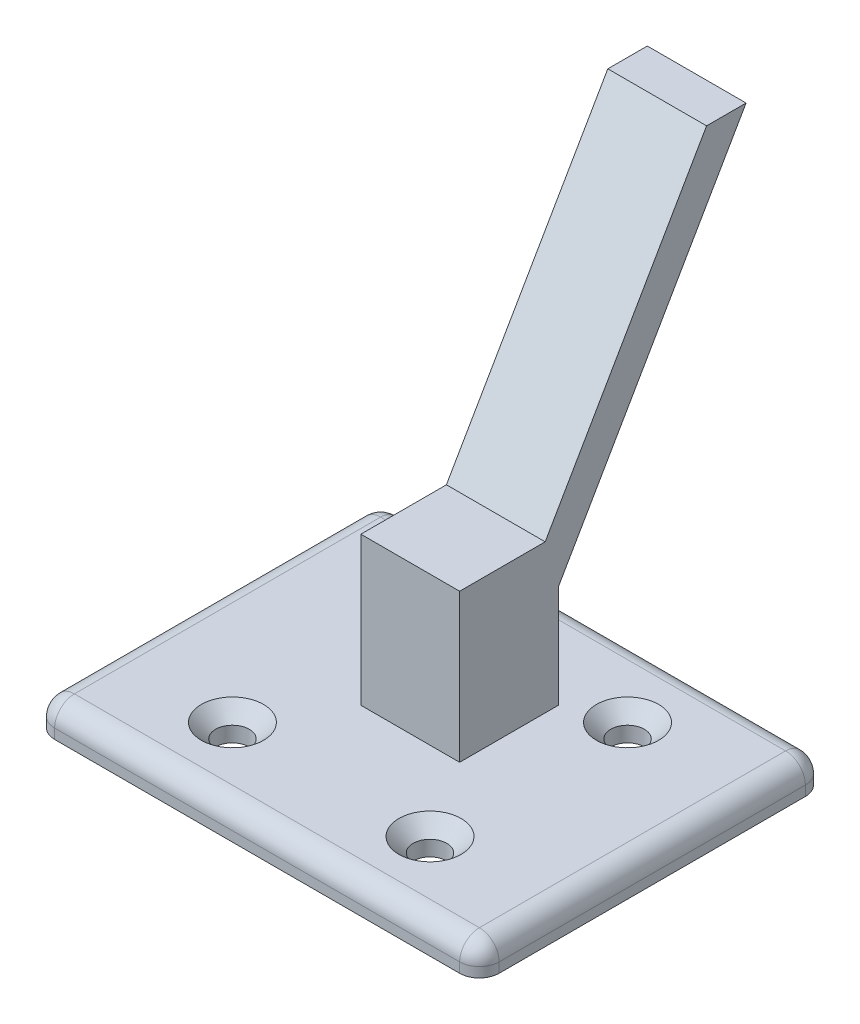
from build123d import *

# Parameters (mm, degrees)
SKETCH1_W                                      = 45
SKETCH1_H                                      = 35
BOSS_EXTRUDE1_DEPTH                            = 3
CSK_FOR_M3_FLAT_HEAD_MACHINE_SCREW2_AT_2_COUNT = 2
CSK_FOR_M3_FLAT_HEAD_MACHINE_SCREW2_AT_2_PITCH = 20
CSK_FOR_M3_FLAT_HEAD_MACHINE_SCREW2_AT_3_COUNT = 2
CSK_FOR_M3_FLAT_HEAD_MACHINE_SCREW2_AT_3_PITCH = 28.284271247
CSK_FOR_M3_FLAT_HEAD_MACHINE_SCREW2_AT_4_COUNT = 2
CSK_FOR_M3_FLAT_HEAD_MACHINE_SCREW2_AT_4_PITCH = 20
SKETCH7_W                                      = 10
SKETCH7_H                                      = 4
BOSS_EXTRUDE2_DEPTH                            = 50
FILLET1_R                                      = 2
SKETCH12_W                                     = 10
SKETCH12_H                                     = 10
BOSS_EXTRUDE3_DEPTH                            = 15


with BuildPart() as part:
    # Sketch1 → Boss-Extrude1 (new body)
    with BuildSketch(Plane(origin=(0, 0, 0), x_dir=(1, 0, 0), z_dir=(0, 1, 0))):
        Rectangle(SKETCH1_W, SKETCH1_H)
    extrude(amount=BOSS_EXTRUDE1_DEPTH)

    # Sketch5 → CSK for M3 Flat Head Machine Screw2 (revolve, cut)
    with BuildSketch(Plane(origin=(10, 3, -10), x_dir=(0, 0, 1), z_dir=(1, 0, 0))):
        Polygon((0, 0), (0, 3), (1.7, 3), (1.7, 1.45), (3.15, 0), align=None)
    csk_for_m3_flat_head_machine_screw2 = revolve(axis=Axis((10, 9.35, -10), (0, -1, 0)), mode=Mode.SUBTRACT)

    # CSK for M3 Flat Head Machine Screw2 at 2: CSK for M3 Flat Head Machine Screw2 ×2
    with Locations(*[(-i * CSK_FOR_M3_FLAT_HEAD_MACHINE_SCREW2_AT_2_PITCH, 0, 0) for i in range(1, CSK_FOR_M3_FLAT_HEAD_MACHINE_SCREW2_AT_2_COUNT)]):
        add(csk_for_m3_flat_head_machine_screw2, mode=Mode.SUBTRACT)

    # CSK for M3 Flat Head Machine Screw2 at 3: CSK for M3 Flat Head Machine Screw2 ×2
    with Locations(*[Vector(-0.707106781, 0, 0.707106781) * (i * CSK_FOR_M3_FLAT_HEAD_MACHINE_SCREW2_AT_3_PITCH) for i in range(1, CSK_FOR_M3_FLAT_HEAD_MACHINE_SCREW2_AT_3_COUNT)]):
        add(csk_for_m3_flat_head_machine_screw2, mode=Mode.SUBTRACT)

    # CSK for M3 Flat Head Machine Screw2 at 4: CSK for M3 Flat Head Machine Screw2 ×2
    with Locations(*[(0, 0, i * CSK_FOR_M3_FLAT_HEAD_MACHINE_SCREW2_AT_4_PITCH) for i in range(1, CSK_FOR_M3_FLAT_HEAD_MACHINE_SCREW2_AT_4_COUNT)]):
        add(csk_for_m3_flat_head_machine_screw2, mode=Mode.SUBTRACT)

    # Sketch7 → Boss-Extrude2 (add, along a direction that is not the sketch's normal)
    with BuildSketch(Plane(origin=(0, 3, 0), x_dir=(1, 0, 0), z_dir=(0, 1, 0))):
        Rectangle(SKETCH7_W, SKETCH7_H)
    extrude(amount=BOSS_EXTRUDE2_DEPTH, dir=(0, 0.866025404, -0.5))

    # Fillet1
    fillet1_edges = [part.edges().sort_by_distance(p)[0] for p in [
        (22.5, 3, 0),
        (0, 3, -17.5),
        (-22.5, 3, 0),
        (0, 3, 17.5),
        (-22.5, 1.5, -17.5),
        (22.5, 1.5, -17.5),
        (22.5, 1.5, 17.5),
        (-22.5, 1.5, 17.5),
    ]]
    fillet(fillet1_edges, radius=FILLET1_R)

    # Sketch12 → Boss-Extrude3 (add)
    with BuildSketch(Plane(origin=(0, 3, 0), x_dir=(1, 0, 0), z_dir=(0, 1, 0))):
        with Locations((0, 3)):
            Rectangle(SKETCH12_W, SKETCH12_H)
    extrude(amount=BOSS_EXTRUDE3_DEPTH)


solid = part.part
